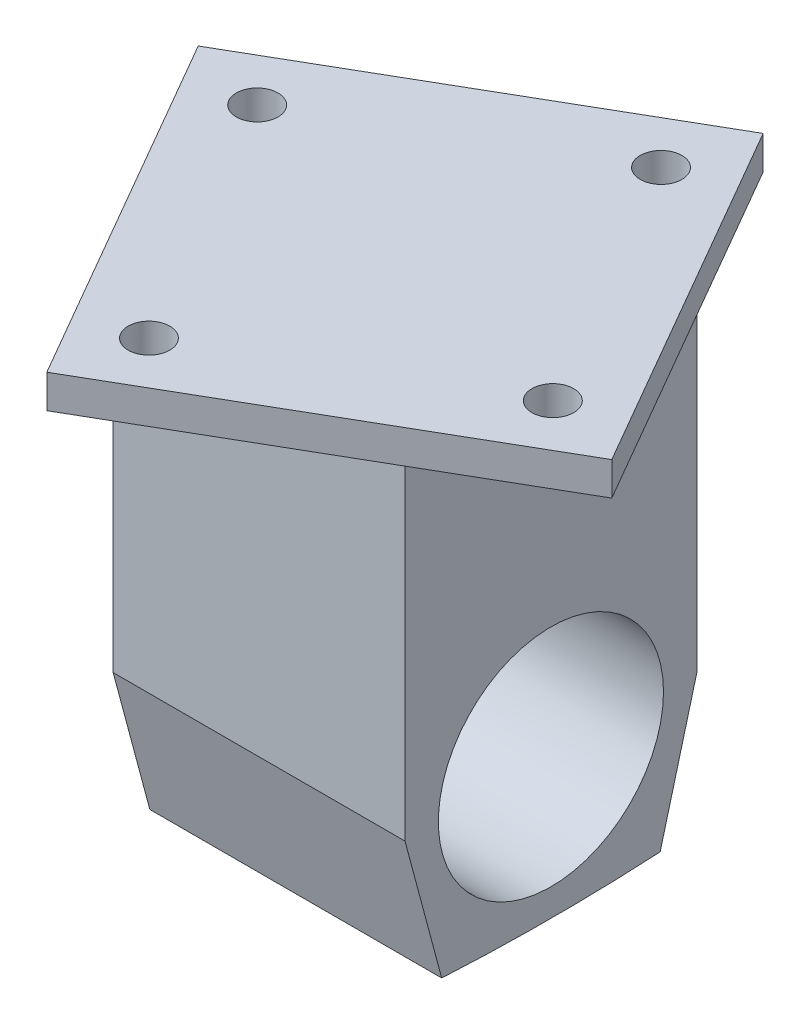
from build123d import *

# Parameters (mm, degrees)
SKETCH1_W           = 44.45
SKETCH1_H           = 44.45
BOSS_EXTRUDE1_DEPTH = 50.292
BOSS_EXTRUDE2_DEPTH = 44.45
SKETCH3_R           = 17.145
CUT_EXTRUDE1_DEPTH  = 127
BOSS_EXTRUDE3_DEPTH = 5.08
SKETCH5_R           = 3.175
CUT_EXTRUDE2_DEPTH  = 77.68803402


with BuildPart() as part:
    # Sketch1 → Boss-Extrude1 (new body)
    with BuildSketch(Plane(origin=(0, 0, 0), x_dir=(1, 0, 0), z_dir=(0, 1, 0))):
        Rectangle(SKETCH1_W, SKETCH1_H)
    extrude(amount=BOSS_EXTRUDE1_DEPTH)

    # Sketch2 → Boss-Extrude2 (add)
    with BuildSketch(Plane(origin=(22.225, 0, 0), x_dir=(0, 0, -1), z_dir=(1, 0, 0))):
        with BuildLine():
            Line((-22.225, 0), (-16.637096816, -20.85433859))
            ThreePointArc((-16.637096816, -20.85433859), (0, -21.31603402), (16.637096816, -20.85433859))
            Line((16.637096816, -20.85433859), (22.225, 0))
            Line((22.225, 0), (-22.225, 0))
        make_face()
    extrude(amount=-BOSS_EXTRUDE2_DEPTH)

    # Sketch3 → Cut-Extrude1 (cut)
    with BuildSketch(Plane(origin=(22.225, 0, 0), x_dir=(0, 0, -1), z_dir=(1, 0, 0))):
        Circle(SKETCH3_R)
    extrude(amount=-CUT_EXTRUDE1_DEPTH, mode=Mode.SUBTRACT)

    # Sketch4 → Boss-Extrude3 (add)
    with BuildSketch(Plane(origin=(0, 50.292, 0), x_dir=(1, 0, 0), z_dir=(0, 1, 0))):
        Polygon((43.024336118, -11.528336118), (-11.528336118, -43.024336118), (-43.024336118, 11.528336118), (11.528336118, 43.024336118), align=None)
    extrude(amount=BOSS_EXTRUDE3_DEPTH)

    # Sketch5 → Cut-Extrude2 (cut, through all)
    with BuildSketch(Plane(origin=(0, 55.372, 0), x_dir=(1, 0, 0), z_dir=(0, 1, 0))):
        with Locations((30.757078124, -8.241334245)):
            Circle(SKETCH5_R)
        with Locations((-8.241334245, -30.757078124)):
            Circle(SKETCH5_R)
        with Locations((8.241334245, 30.757078124)):
            Circle(SKETCH5_R)
        with Locations((-30.757078124, 8.241334245)):
            Circle(SKETCH5_R)
    extrude(amount=-CUT_EXTRUDE2_DEPTH, mode=Mode.SUBTRACT)


solid = part.part
